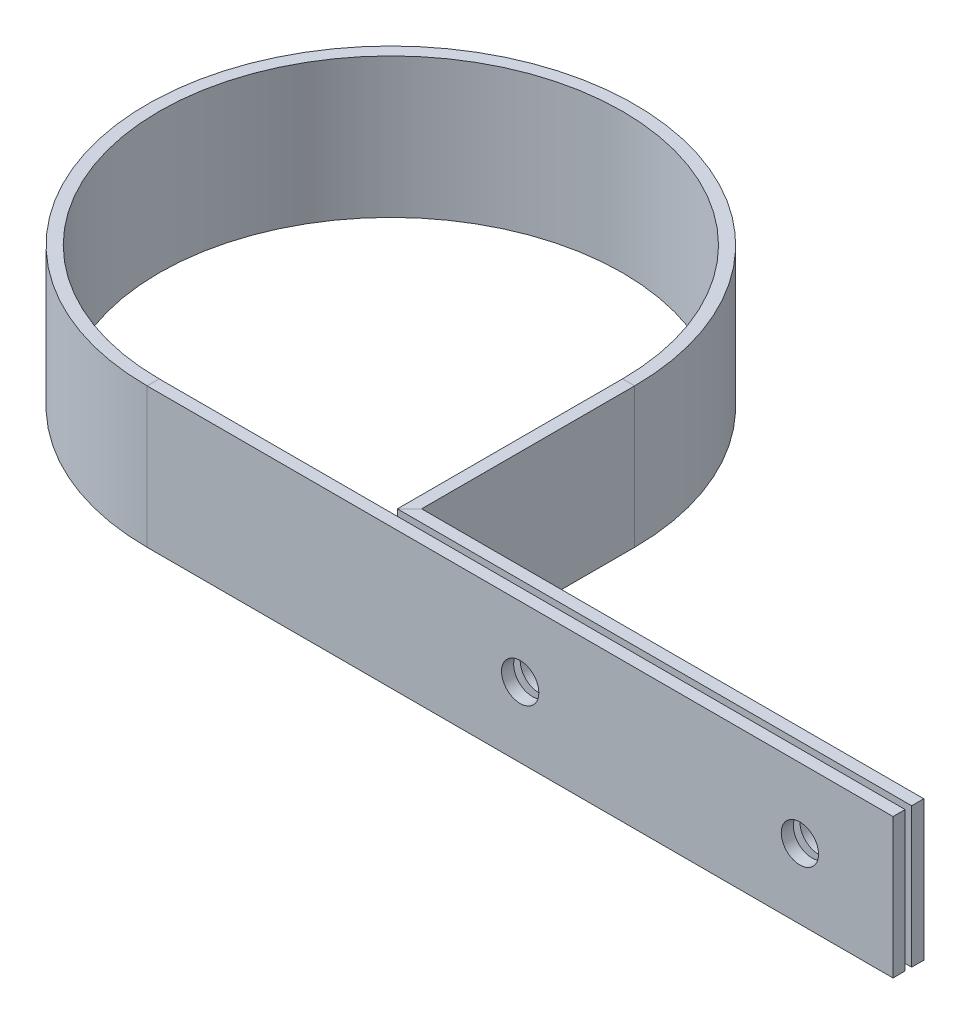
from build123d import *

# Parameters (mm, degrees)
SKETCH2_W          = 1.651
SKETCH2_H          = 19.05
SKETCH3_R          = 2.54
CUT_EXTRUDE1_DEPTH = 5.191001743


with BuildPart() as part:
    # Sweep1: sweep along a path in Sketch1
    with BuildLine(Plane(origin=(0, 0, 0), x_dir=(1, 0, 0), z_dir=(0, 1, 0))) as sweep1_path:
        Line((0, 0), (-101.6, 0))
        ThreePointArc((-101.6, 0), (-124.514215323, 55.280847216), (-69.225758741, 32.384998213))
        Line((-69.225758741, 32.384998213), (-69.225758741, 2.54))
        Line((-69.225758741, 2.54), (0, 2.54))
    # Sketch2 → Sweep1 (sweep)
    with BuildSketch(Plane(origin=(0, 0, 0), x_dir=(0, 0, -1), z_dir=(1, 0, 0))):
        Rectangle(SKETCH2_W, SKETCH2_H)
    sweep(path=sweep1_path.line, transition=Transition.RIGHT)

    # Sketch3 → Cut-Extrude1 (cut, through all)
    with BuildSketch(Plane(origin=(0, 0, -3.3655), x_dir=(-1, 0, 0), z_dir=(0, 0, -1))):
        with Locations((50.787439211, 0)):
            Circle(SKETCH3_R)
        with Locations((12.687439211, 0)):
            Circle(SKETCH3_R)
    extrude(amount=-CUT_EXTRUDE1_DEPTH, mode=Mode.SUBTRACT)


solid = part.part
